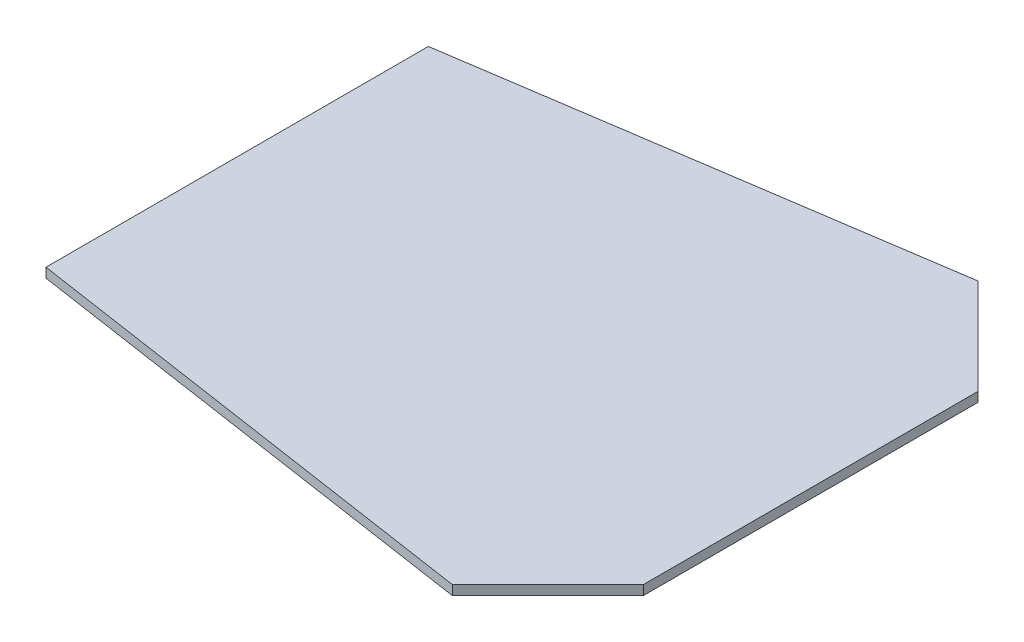
from build123d import *

# Parameters (mm, degrees)
BOSS_EXTRUDE1_DEPTH = 5


with BuildPart() as part:
    # Sketch1 → Boss-Extrude1 (new body, symmetric)
    with BuildSketch(Plane(origin=(0, 0, 0), x_dir=(1, 0, 0), z_dir=(0, 1, 0))):
        Polygon((0, 200), (0, -200), (500, -275), (600, -175), (600, 175), (500, 275), align=None)
    extrude(amount=BOSS_EXTRUDE1_DEPTH, both=True)


solid = part.part
